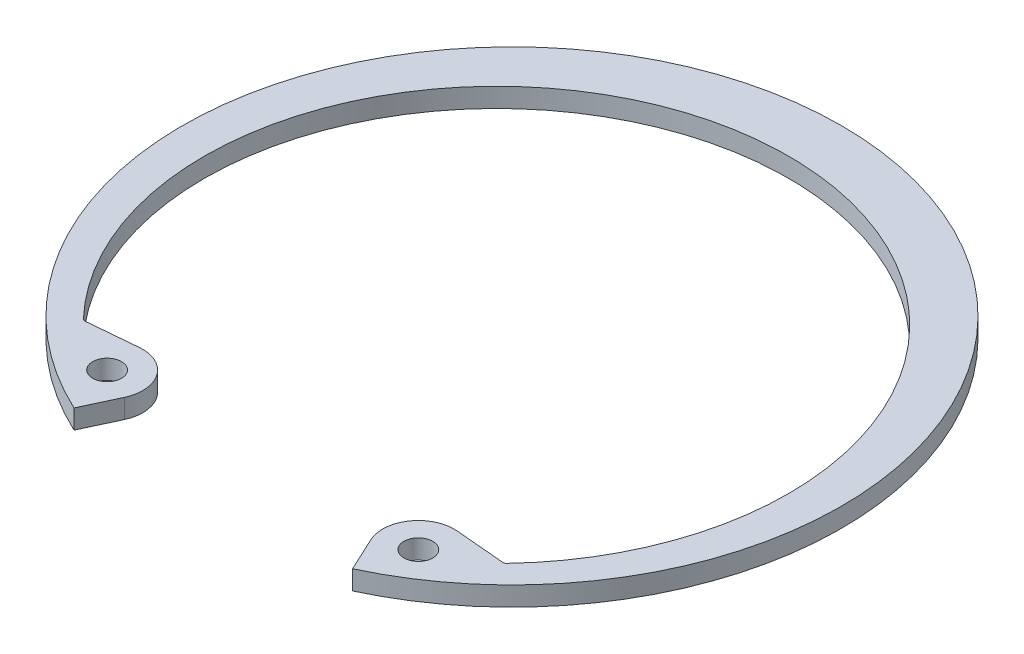
from build123d import *

# Parameters (mm, degrees)
SKETCH2_R      = 1.1811
EXTRUDE1_DEPTH = 1.5748
FILLET1_R      = 0.254


with BuildPart() as part:
    # Sketch2 → Extrude1 (new body)
    with BuildSketch(Plane(origin=(0, 0, 0), x_dir=(1, 0, 0), z_dir=(0, 1, 0))):
        with BuildLine():
            Line((11.389308583, -24.424451076), (10.079527634, -21.615616767))
            ThreePointArc((10.079527634, -21.615616767), (10.334109559, -18.705732054), (12.981434605, -17.471264112))
            Line((12.981434605, -17.471264112), (17.211887304, -17.841380764))
            ThreePointArc((17.211887304, -17.841380764), (0, 22.6314), (-17.211887304, -17.841380764))
            Line((-17.211887304, -17.841380764), (-12.981434605, -17.471264112))
            ThreePointArc((-12.981434605, -17.471264112), (-10.334109559, -18.705732054), (-10.079527634, -21.615616767))
            Line((-10.079527634, -21.615616767), (-11.389308583, -24.424451076))
            ThreePointArc((-11.389308583, -24.424451076), (0, 26.9494), (11.389308583, -24.424451076))
        make_face()
        with Locations((12.72685268, -20.381148825)):
            Circle(SKETCH2_R, mode=Mode.SUBTRACT)
        with Locations((-12.72685268, -20.381148825)):
            Circle(SKETCH2_R, mode=Mode.SUBTRACT)
    extrude(amount=-EXTRUDE1_DEPTH)

    # Fillet1
    fillet1_edges = [part.edges().sort_by_distance(p)[0] for p in [
        (17.211887304, -0.7874, 17.841380764),
        (-17.211887304, -0.7874, 17.841380764),
    ]]
    fillet(fillet1_edges, radius=FILLET1_R)


solid = part.part
